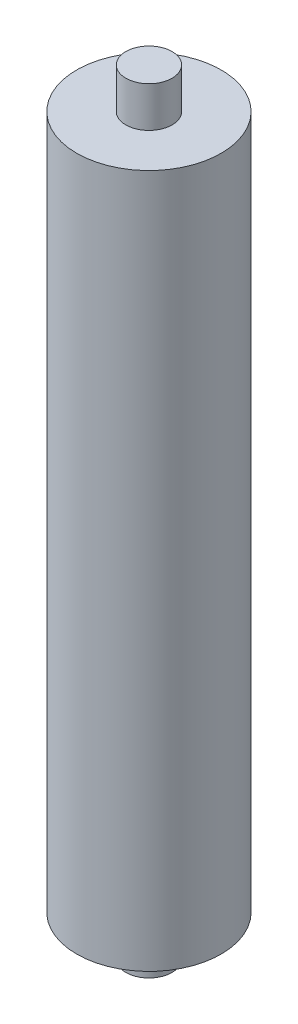
from build123d import *

# Parameters (mm, degrees)
BOSS_EXTRUDE1_DEPTH      = 60
BOSS_EXTRUDE1_DEPTH_BACK = 60
SKETCH1_R                = 12.5
SKETCH2_R                = 4
BOSS_EXTRUDE2_DEPTH      = 7
BOSS_EXTRUDE3_START      = 7
SKETCH3_R                = 4
BOSS_EXTRUDE3_DEPTH      = 7


with BuildPart() as part:
    # Sketch1 → Boss-Extrude1 (new, two sides: drawn at the far end of the back side and taken through both)
    with BuildSketch(Plane(origin=(0, 0, 0), x_dir=(1, 0, 0), z_dir=(0, 1, 0)).offset(-BOSS_EXTRUDE1_DEPTH_BACK)):
        Circle(SKETCH1_R)
    extrude(amount=BOSS_EXTRUDE1_DEPTH + BOSS_EXTRUDE1_DEPTH_BACK)

    # Sketch2 → Boss-Extrude2 (add)
    with BuildSketch(Plane(origin=(0, 60, 0), x_dir=(1, 0, 0), z_dir=(0, 1, 0))):
        Circle(SKETCH2_R)
    extrude(amount=BOSS_EXTRUDE2_DEPTH)

    # Sketch3 → Boss-Extrude3 (add)
    with BuildSketch(Plane.XZ.offset(60).offset(BOSS_EXTRUDE3_START)):
        Circle(SKETCH3_R)
    extrude(amount=-BOSS_EXTRUDE3_DEPTH)


solid = part.part
